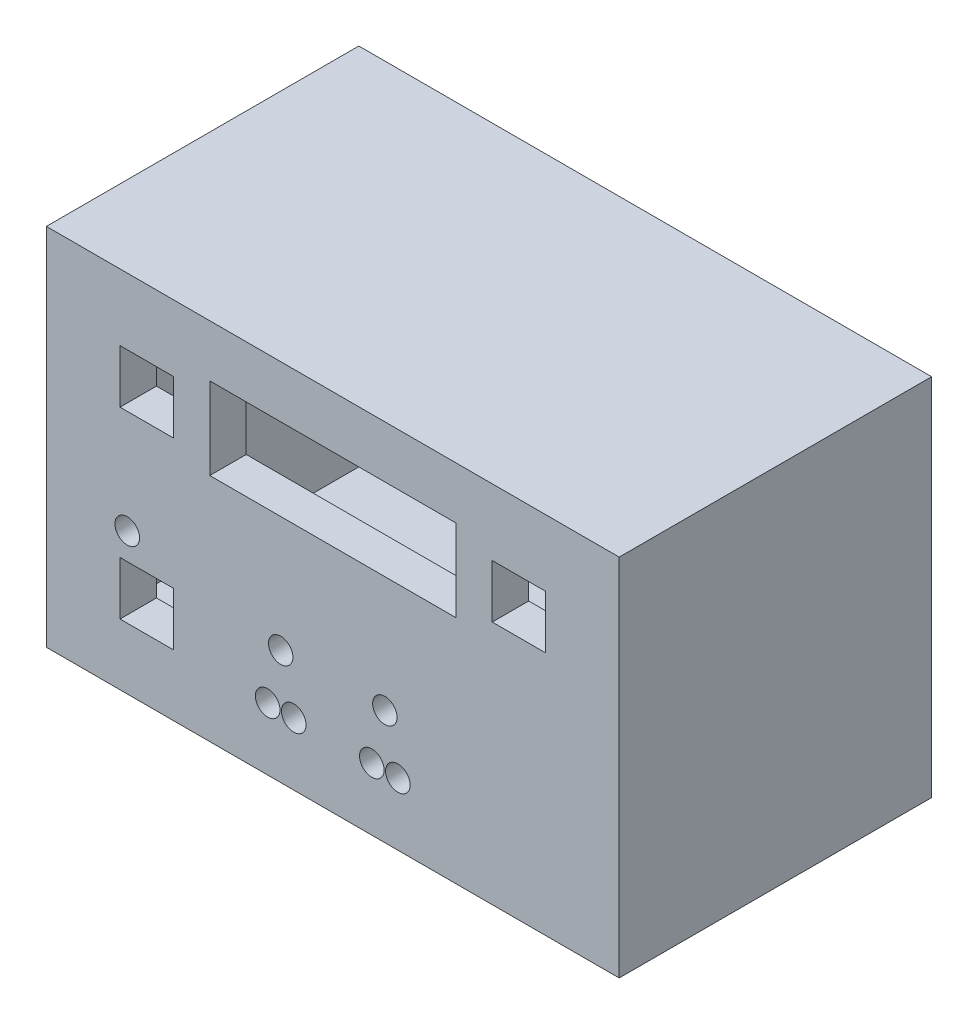
from build123d import *

# Parameters (mm, degrees)
SKETCH1_W           = 127
SKETCH1_H           = 76.2
SKETCH1_R           = 2.978797174
SKETCH1_R_2         = 3
SKETCH1_W_2         = 60
SKETCH1_H_2         = 20
SKETCH1_W_3         = 13
SKETCH1_H_3         = 13
BOSS_EXTRUDE1_DEPTH = 8.89
SKETCH3_W           = 127
SKETCH3_H           = 76.2
SKETCH3_R           = 5.518797174
SKETCH3_W_2         = 18.08
SKETCH3_H_2         = 18.08
SKETCH3_R_2         = 3
SKETCH3_W_3         = 65.08
SKETCH3_H_3         = 25.08
CUT_EXTRUDE1_DEPTH  = 3.81
BOSS_EXTRUDE2_START = -5.08
SKETCH5_W           = 129.54
SKETCH5_H           = 78.74
SKETCH5_W_2         = 127
SKETCH5_H_2         = 76.2
BOSS_EXTRUDE2_DEPTH = 5.08
SKETCH6_W           = 139.7
SKETCH6_H           = 88.9
SKETCH6_W_2         = 129.54
SKETCH6_H_2         = 78.74
BOSS_EXTRUDE3_DEPTH = 76.2
CUT_EXTRUDE3_REACH  = 141.7
SKETCH7_W           = 6.952697557
SKETCH7_H           = 10.320960494


with BuildPart() as part:
    # Sketch1 → Boss-Extrude1 (new body)
    with BuildSketch(Plane.XY):
        Rectangle(SKETCH1_W, SKETCH1_H)
        with Locations((-12.7, -16.51)):
            Circle(SKETCH1_R, mode=Mode.SUBTRACT)
        with Locations((12.7, -16.51)):
            Circle(SKETCH1_R, mode=Mode.SUBTRACT)
        with Locations((-15.875, -29.21)):
            Circle(SKETCH1_R_2, mode=Mode.SUBTRACT)
        with Locations((-9.525, -29.21)):
            Circle(SKETCH1_R_2, mode=Mode.SUBTRACT)
        with Locations((9.525, -29.21)):
            Circle(SKETCH1_R_2, mode=Mode.SUBTRACT)
        with Locations((15.875, -29.21)):
            Circle(SKETCH1_R_2, mode=Mode.SUBTRACT)
        with Locations((-50.124380999, -10.001211499)):
            Circle(SKETCH1_R_2, mode=Mode.SUBTRACT)
        with Locations((0, 21.75)):
            Rectangle(SKETCH1_W_2, SKETCH1_H_2, mode=Mode.SUBTRACT)
        with Locations((-45.39, 21.75)):
            Rectangle(SKETCH1_W_3, SKETCH1_H_3, mode=Mode.SUBTRACT)
        with Locations((45.39, 21.75)):
            Rectangle(SKETCH1_W_3, SKETCH1_H_3, mode=Mode.SUBTRACT)
        with Locations((-45.39, -22.996165479)):
            Rectangle(SKETCH1_W_3, SKETCH1_H_3, mode=Mode.SUBTRACT)
    extrude(amount=BOSS_EXTRUDE1_DEPTH)

    # Sketch3 → Cut-Extrude1 (cut)
    with BuildSketch(Plane(origin=(0, 0, 0), x_dir=(-1, 0, 0), z_dir=(0, 0, -1))):
        Rectangle(SKETCH3_W, SKETCH3_H)
        with BuildLine():
            ThreePointArc((-12.7, -24.670068833), (-6.965498095, -24.296696631), (-3.985, -29.21))
            ThreePointArc((-3.985, -29.21), (-6.965498095, -34.123303369), (-12.7, -33.749931167))
            ThreePointArc((-12.7, -33.749931167), (-21.415, -29.21), (-12.7, -24.670068833))
        make_face(mode=Mode.SUBTRACT)
        with Locations((-12.7, -16.51)):
            Circle(SKETCH3_R, mode=Mode.SUBTRACT)
        with BuildLine():
            ThreePointArc((12.7, -24.670068833), (18.434501905, -24.296696631), (21.415, -29.21))
            ThreePointArc((21.415, -29.21), (18.434501905, -34.123303369), (12.7, -33.749931167))
            ThreePointArc((12.7, -33.749931167), (3.985, -29.21), (12.7, -24.670068833))
        make_face(mode=Mode.SUBTRACT)
        with Locations((45.39, -22.996165479)):
            Rectangle(SKETCH3_W_2, SKETCH3_H_2, mode=Mode.SUBTRACT)
        with Locations((12.7, -16.51)):
            Circle(SKETCH3_R, mode=Mode.SUBTRACT)
        with Locations((50.124380999, -10.001211499)):
            Circle(SKETCH3_R_2, mode=Mode.SUBTRACT)
        with Locations((-45.39, 21.75)):
            Rectangle(SKETCH3_W_2, SKETCH3_H_2, mode=Mode.SUBTRACT)
        with Locations((0, 21.75)):
            Rectangle(SKETCH3_W_3, SKETCH3_H_3, mode=Mode.SUBTRACT)
        with Locations((45.39, 21.75)):
            Rectangle(SKETCH3_W_2, SKETCH3_H_2, mode=Mode.SUBTRACT)
    extrude(amount=-CUT_EXTRUDE1_DEPTH, mode=Mode.SUBTRACT)

    # Sketch5 → Boss-Extrude2 (add)
    with BuildSketch(Plane.XY.offset(8.89).offset(BOSS_EXTRUDE2_START)):
        Rectangle(SKETCH5_W, SKETCH5_H)
        Rectangle(SKETCH5_W_2, SKETCH5_H_2, mode=Mode.SUBTRACT)
    extrude(amount=BOSS_EXTRUDE2_DEPTH)

    # Sketch6 → Boss-Extrude3 (add)
    with BuildSketch(Plane.XY.offset(8.89)):
        Rectangle(SKETCH6_W, SKETCH6_H)
        Rectangle(SKETCH6_W_2, SKETCH6_H_2, mode=Mode.SUBTRACT)
    extrude(amount=-BOSS_EXTRUDE3_DEPTH)

    # Sketch7 → Cut-Extrude3 (cut, up to next)
    with BuildSketch(Plane.ZY.offset(69.85), mode=Mode.PRIVATE) as cut_extrude3_sk1:
        with Locations((0.333651222, 1.522792989)):
            Rectangle(SKETCH7_W, SKETCH7_H)
    cut_extrude3_tool1 = extrude(cut_extrude3_sk1.sketch, amount=-CUT_EXTRUDE3_REACH, mode=Mode.PRIVATE) & part.part
    add(cut_extrude3_tool1.solids().sort_by_distance((-69.85, 1.522793, 0.333651))[0], mode=Mode.SUBTRACT)


solid = part.part
